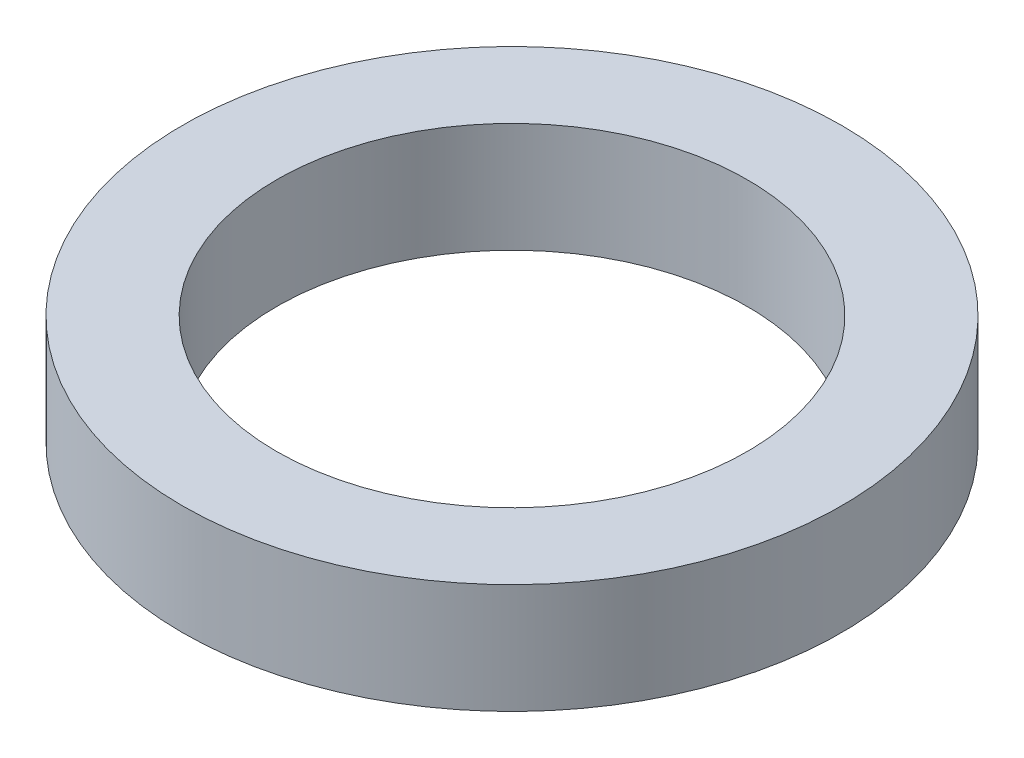
from build123d import *

# Parameters (mm, degrees)
SKETCH1_W = 6
SKETCH1_H = 7


with BuildPart() as part:
    # Sketch1 → Revolve1 (revolve)
    with BuildSketch(Plane.XY):
        with Locations((18, 0)):
            Rectangle(SKETCH1_W, SKETCH1_H)
    revolve(axis=Axis((0, 3.5, 0), (0, -1, 0)))


solid = part.part
